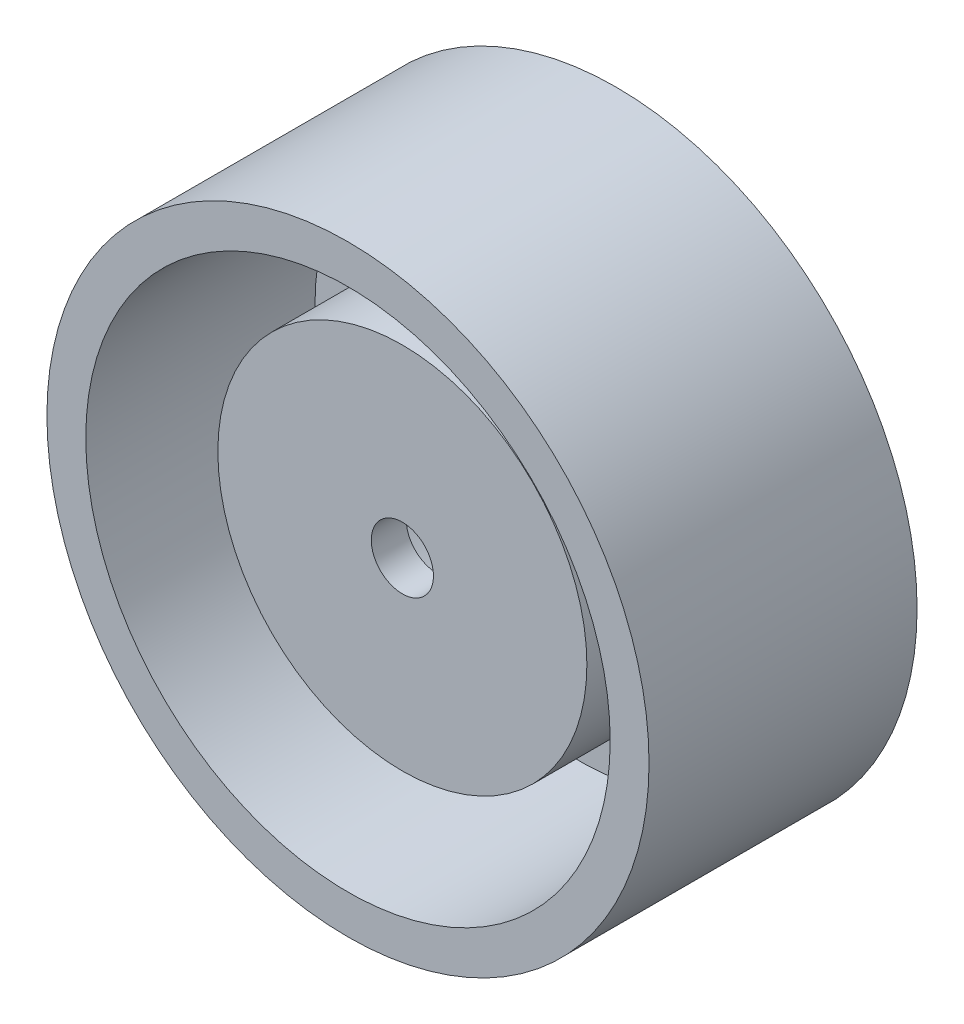
from build123d import *

# Parameters (mm, degrees)
SKETCH1_R           = 19.685
BOSS_EXTRUDE4_DEPTH = 17.526
SHELL1_T            = -2.54
SKETCH2_R           = 12.065
BOSS_EXTRUDE5_DEPTH = 11.43
SKETCH3_R           = 10.795
CUT_EXTRUDE1_DEPTH  = 11.684
SKETCH4_R           = 2.032
CUT_EXTRUDE2_DEPTH  = 2.54


with BuildPart() as part:
    # Sketch1 → Boss-Extrude4 (new body)
    with BuildSketch(Plane.XY):
        with Locations((-69.769461907, 37.477045181)):
            Circle(SKETCH1_R)
    extrude(amount=BOSS_EXTRUDE4_DEPTH)

    # Shell1
    shell1_openings = [part.faces().sort_by_distance(p)[0] for p in [
        (-69.769461907, 37.477045181, 17.526),
    ]]
    offset(amount=SHELL1_T, openings=shell1_openings, kind=Kind.INTERSECTION)

    # Sketch2 → Boss-Extrude5 (add)
    with BuildSketch(Plane.XY.offset(2.54)):
        with Locations((-69.769461907, 37.477045181)):
            Circle(SKETCH2_R)
    extrude(amount=BOSS_EXTRUDE5_DEPTH)

    # Sketch3 → Cut-Extrude1 (cut)
    with BuildSketch(Plane(origin=(0, 0, 0), x_dir=(-1, 0, 0), z_dir=(0, 0, -1))):
        with Locations((69.769461907, 37.477045181)):
            Circle(SKETCH3_R)
    extrude(amount=-CUT_EXTRUDE1_DEPTH, mode=Mode.SUBTRACT)

    # Sketch4 → Cut-Extrude2 (cut)
    with BuildSketch(Plane.XY.offset(13.97)):
        with Locations((-69.769461907, 37.477045181)):
            Circle(SKETCH4_R)
    extrude(amount=-CUT_EXTRUDE2_DEPTH, mode=Mode.SUBTRACT)


solid = part.part
